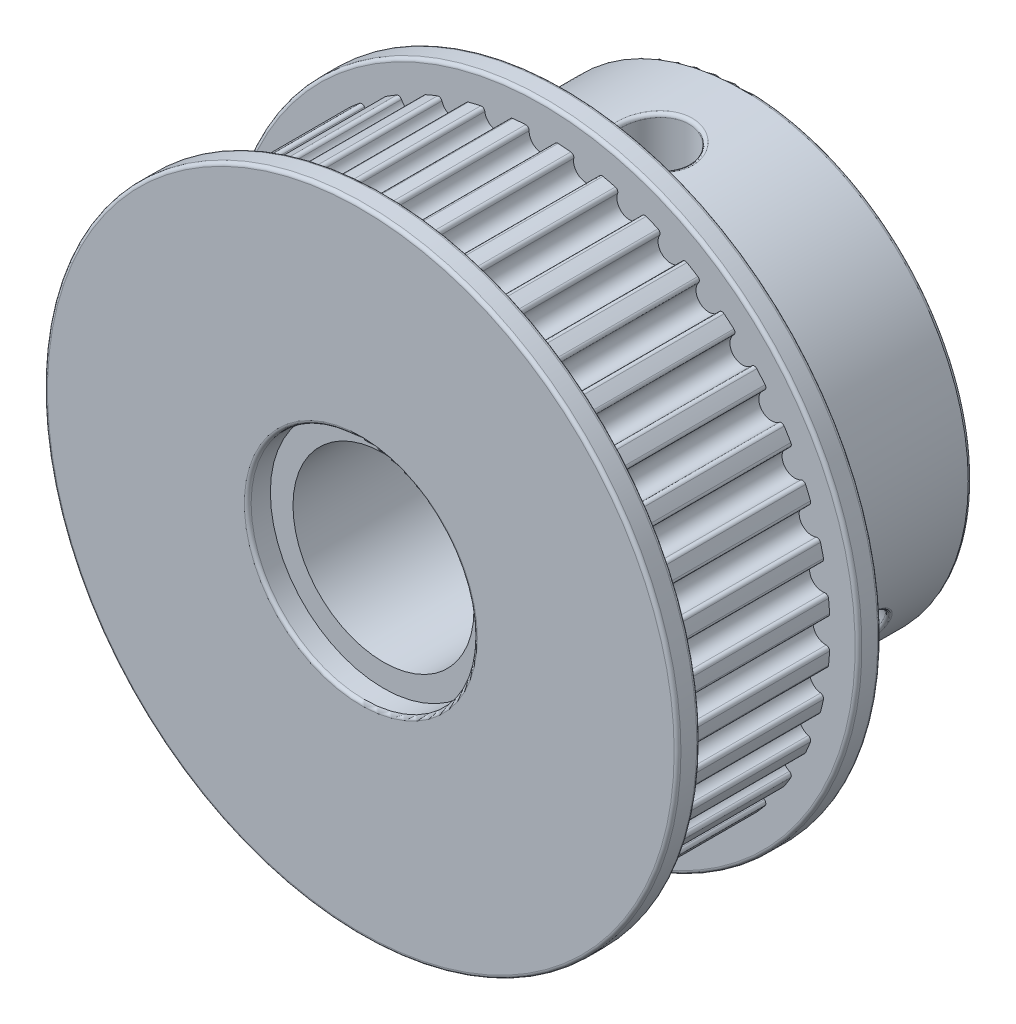
from build123d import *

# Parameters (mm, degrees)
IZIM1_R                     = 4
Y_KSEKLIK_EKSTR_ZYON1_DEPTH = 7
IZIM2_R                     = 14
IZIM2_R_2                   = 5
Y_KSEKLIK_EKSTR_ZYON2_DEPTH = 1
IZIM3_R                     = 14
IZIM3_R_2                   = 4
Y_KSEKLIK_EKSTR_ZYON3_DEPTH = 1
IZIM4_R                     = 10
IZIM4_R_2                   = 4
Y_KSEKLIK_EKSTR_ZYON4_DEPTH = 8
IZIM5_R                     = 1.5
KES_EKSTR_ZYON1_DEPTH       = 11
DAIRESEL_KAPLAMA1_COUNT     = 3
RADYUS1_R                   = 0.15


with BuildPart() as part:
    # Çizim1 → Yükseklik-Ekstrüzyon1 (new body)
    with BuildSketch(Plane.XY):
        with BuildLine():
            ThreePointArc((-0.718175382, 12.718593189), (-0.999478926, 12.699583869), (-1.280292871, 12.674353583))
            ThreePointArc((-1.280292871, 12.674353583), (-1.385311882, 12.614986985), (-1.412651738, 12.497488398))
            ThreePointArc((-1.412651738, 12.497488398), (-1.875469884, 11.841250822), (-2.518424661, 12.322351173))
            ThreePointArc((-2.518424661, 12.322351173), (-2.58073547, 12.425650489), (-2.698959772, 12.44965882))
            ThreePointArc((-2.698959772, 12.44965882), (-2.973826291, 12.386877967), (-3.247236063, 12.318029328))
            ThreePointArc((-3.247236063, 12.318029328), (-3.341675134, 12.242965039), (-3.350297563, 12.122636159))
            ThreePointArc((-3.350297563, 12.122636159), (-3.704759476, 11.402077247), (-4.415059088, 11.776674167))
            ThreePointArc((-4.415059088, 11.776674167), (-4.492762321, 11.86895414), (-4.613286816, 11.874172532))
            ThreePointArc((-4.613286816, 11.874172532), (-4.874948183, 11.769166019), (-5.134221527, 11.65839431))
            ThreePointArc((-5.134221527, 11.65839431), (-5.215755254, 11.569480661), (-5.205447943, 11.449284384))
            ThreePointArc((-5.205447943, 11.449284384), (-5.442825593, 10.682146689), (-6.202980108, 10.941016359))
            ThreePointArc((-6.202980108, 10.941016359), (-6.294162453, 11.020004749), (-6.414019428, 11.006304709))
            ThreePointArc((-6.414019428, 11.006304709), (-6.656032672, 10.861658145), (-6.894785417, 10.711690932))
            ThreePointArc((-6.894785417, 10.711690932), (-6.96140617, 10.611117273), (-6.932422918, 10.49401323))
            ThreePointArc((-6.932422918, 10.49401323), (-7.046871281, 9.699186227), (-7.838163171, 9.835954418))
            ThreePointArc((-7.838163171, 9.835954418), (-7.940579416, 9.899706267), (-8.056817595, 9.867425136))
            ThreePointArc((-8.056817595, 9.867425136), (-8.273223546, 9.686700199), (-8.485576808, 9.501230173))
            ThreePointArc((-8.485576808, 9.501230173), (-8.535644163, 9.391472961), (-8.488698634, 9.280344643))
            ThreePointArc((-8.488698634, 9.280344643), (-8.477399611, 8.477399611), (-9.280344643, 8.488698634))
            ThreePointArc((-9.280344643, 8.488698634), (-9.391472961, 8.535644163), (-9.501230173, 8.485576808))
            ThreePointArc((-9.501230173, 8.485576808), (-9.686700199, 8.273223546), (-9.867425136, 8.056817595))
            ThreePointArc((-9.867425136, 8.056817595), (-9.899706267, 7.940579416), (-9.835954418, 7.838163171))
            ThreePointArc((-9.835954418, 7.838163171), (-9.699186227, 7.046871281), (-10.49401323, 6.932422918))
            ThreePointArc((-10.49401323, 6.932422918), (-10.611117273, 6.96140617), (-10.711690932, 6.894785417))
            ThreePointArc((-10.711690932, 6.894785417), (-10.861658145, 6.656032672), (-11.006304709, 6.414019428))
            ThreePointArc((-11.006304709, 6.414019428), (-11.020004749, 6.294162453), (-10.941016359, 6.202980108))
            ThreePointArc((-10.941016359, 6.202980108), (-10.682146689, 5.442825593), (-11.449284384, 5.205447943))
            ThreePointArc((-11.449284384, 5.205447943), (-11.569480661, 5.215755254), (-11.65839431, 5.134221527))
            ThreePointArc((-11.65839431, 5.134221527), (-11.769166019, 4.874948183), (-11.874172532, 4.613286816))
            ThreePointArc((-11.874172532, 4.613286816), (-11.86895414, 4.492762321), (-11.776674167, 4.415059088))
            ThreePointArc((-11.776674167, 4.415059088), (-11.402077247, 3.704759476), (-12.122636159, 3.350297563))
            ThreePointArc((-12.122636159, 3.350297563), (-12.242965039, 3.341675134), (-12.318029328, 3.247236063))
            ThreePointArc((-12.318029328, 3.247236063), (-12.386877967, 2.973826291), (-12.44965882, 2.698959772))
            ThreePointArc((-12.44965882, 2.698959772), (-12.425650489, 2.58073547), (-12.322351173, 2.518424661))
            ThreePointArc((-12.322351173, 2.518424661), (-11.841250822, 1.875469884), (-12.497488398, 1.412651738))
            ThreePointArc((-12.497488398, 1.412651738), (-12.614986985, 1.385311882), (-12.674353583, 1.280292871))
            ThreePointArc((-12.674353583, 1.280292871), (-12.699583869, 0.999478926), (-12.718593189, 0.718175382))
            ThreePointArc((-12.718593189, 0.718175382), (-12.676386085, 0.605162347), (-12.564610997, 0.559778261))
            ThreePointArc((-12.564610997, 0.559778261), (-11.988853503, 0), (-12.564610997, -0.559778261))
            ThreePointArc((-12.564610997, -0.559778261), (-12.676386085, -0.605162347), (-12.718593189, -0.718175382))
            ThreePointArc((-12.718593189, -0.718175382), (-12.699583869, -0.999478926), (-12.674353583, -1.280292871))
            ThreePointArc((-12.674353583, -1.280292871), (-12.614986985, -1.385311882), (-12.497488398, -1.412651738))
            ThreePointArc((-12.497488398, -1.412651738), (-11.841250822, -1.875469884), (-12.322351173, -2.518424661))
            ThreePointArc((-12.322351173, -2.518424661), (-12.425650489, -2.58073547), (-12.44965882, -2.698959772))
            ThreePointArc((-12.44965882, -2.698959772), (-12.386877967, -2.973826291), (-12.318029328, -3.247236063))
            ThreePointArc((-12.318029328, -3.247236063), (-12.242965039, -3.341675134), (-12.122636159, -3.350297563))
            ThreePointArc((-12.122636159, -3.350297563), (-11.402077247, -3.704759476), (-11.776674167, -4.415059088))
            ThreePointArc((-11.776674167, -4.415059088), (-11.86895414, -4.492762321), (-11.874172532, -4.613286816))
            ThreePointArc((-11.874172532, -4.613286816), (-11.769166019, -4.874948183), (-11.65839431, -5.134221527))
            ThreePointArc((-11.65839431, -5.134221527), (-11.569480661, -5.215755254), (-11.449284384, -5.205447943))
            ThreePointArc((-11.449284384, -5.205447943), (-10.682146689, -5.442825593), (-10.941016359, -6.202980108))
            ThreePointArc((-10.941016359, -6.202980108), (-11.020004749, -6.294162453), (-11.006304709, -6.414019428))
            ThreePointArc((-11.006304709, -6.414019428), (-10.861658145, -6.656032672), (-10.711690932, -6.894785417))
            ThreePointArc((-10.711690932, -6.894785417), (-10.611117273, -6.96140617), (-10.49401323, -6.932422918))
            ThreePointArc((-10.49401323, -6.932422918), (-9.699186227, -7.046871281), (-9.835954418, -7.838163171))
            ThreePointArc((-9.835954418, -7.838163171), (-9.899706267, -7.940579416), (-9.867425136, -8.056817595))
            ThreePointArc((-9.867425136, -8.056817595), (-9.686700199, -8.273223546), (-9.501230173, -8.485576808))
            ThreePointArc((-9.501230173, -8.485576808), (-9.391472961, -8.535644163), (-9.280344643, -8.488698634))
            ThreePointArc((-9.280344643, -8.488698634), (-8.477399611, -8.477399611), (-8.488698634, -9.280344643))
            ThreePointArc((-8.488698634, -9.280344643), (-8.535644163, -9.391472961), (-8.485576808, -9.501230173))
            ThreePointArc((-8.485576808, -9.501230173), (-8.273223546, -9.686700199), (-8.056817595, -9.867425136))
            ThreePointArc((-8.056817595, -9.867425136), (-7.940579416, -9.899706267), (-7.838163171, -9.835954418))
            ThreePointArc((-7.838163171, -9.835954418), (-7.046871281, -9.699186227), (-6.932422918, -10.49401323))
            ThreePointArc((-6.932422918, -10.49401323), (-6.96140617, -10.611117273), (-6.894785417, -10.711690932))
            ThreePointArc((-6.894785417, -10.711690932), (-6.656032672, -10.861658145), (-6.414019428, -11.006304709))
            ThreePointArc((-6.414019428, -11.006304709), (-6.294162453, -11.020004749), (-6.202980108, -10.941016359))
            ThreePointArc((-6.202980108, -10.941016359), (-5.442825593, -10.682146689), (-5.205447943, -11.449284384))
            ThreePointArc((-5.205447943, -11.449284384), (-5.215755254, -11.569480661), (-5.134221527, -11.65839431))
            ThreePointArc((-5.134221527, -11.65839431), (-4.874948183, -11.769166019), (-4.613286816, -11.874172532))
            ThreePointArc((-4.613286816, -11.874172532), (-4.492762321, -11.86895414), (-4.415059088, -11.776674167))
            ThreePointArc((-4.415059088, -11.776674167), (-3.704759476, -11.402077247), (-3.350297563, -12.122636159))
            ThreePointArc((-3.350297563, -12.122636159), (-3.341675134, -12.242965039), (-3.247236063, -12.318029328))
            ThreePointArc((-3.247236063, -12.318029328), (-2.973826291, -12.386877967), (-2.698959772, -12.44965882))
            ThreePointArc((-2.698959772, -12.44965882), (-2.58073547, -12.425650489), (-2.518424661, -12.322351173))
            ThreePointArc((-2.518424661, -12.322351173), (-1.875469884, -11.841250822), (-1.412651738, -12.497488398))
            ThreePointArc((-1.412651738, -12.497488398), (-1.385311882, -12.614986985), (-1.280292871, -12.674353583))
            ThreePointArc((-1.280292871, -12.674353583), (-0.999478926, -12.699583869), (-0.718175382, -12.718593189))
            ThreePointArc((-0.718175382, -12.718593189), (-0.605162347, -12.676386085), (-0.559778261, -12.564610997))
            ThreePointArc((-0.559778261, -12.564610997), (0, -11.988853503), (0.559778261, -12.564610997))
            ThreePointArc((0.559778261, -12.564610997), (0.605162347, -12.676386085), (0.718175382, -12.718593189))
            ThreePointArc((0.718175382, -12.718593189), (0.999478926, -12.699583869), (1.280292871, -12.674353583))
            ThreePointArc((1.280292871, -12.674353583), (1.385311882, -12.614986985), (1.412651738, -12.497488398))
            ThreePointArc((1.412651738, -12.497488398), (1.875469884, -11.841250822), (2.518424661, -12.322351173))
            ThreePointArc((2.518424661, -12.322351173), (2.58073547, -12.425650489), (2.698959772, -12.44965882))
            ThreePointArc((2.698959772, -12.44965882), (2.973826291, -12.386877967), (3.247236063, -12.318029328))
            ThreePointArc((3.247236063, -12.318029328), (3.341675134, -12.242965039), (3.350297563, -12.122636159))
            ThreePointArc((3.350297563, -12.122636159), (3.704759476, -11.402077247), (4.415059088, -11.776674167))
            ThreePointArc((4.415059088, -11.776674167), (4.492762321, -11.86895414), (4.613286816, -11.874172532))
            ThreePointArc((4.613286816, -11.874172532), (4.874948183, -11.769166019), (5.134221527, -11.65839431))
            ThreePointArc((5.134221527, -11.65839431), (5.215755254, -11.569480661), (5.205447943, -11.449284384))
            ThreePointArc((5.205447943, -11.449284384), (5.442825593, -10.682146689), (6.202980108, -10.941016359))
            ThreePointArc((6.202980108, -10.941016359), (6.294162453, -11.020004749), (6.414019428, -11.006304709))
            ThreePointArc((6.414019428, -11.006304709), (6.656032672, -10.861658145), (6.894785417, -10.711690932))
            ThreePointArc((6.894785417, -10.711690932), (6.96140617, -10.611117273), (6.932422918, -10.49401323))
            ThreePointArc((6.932422918, -10.49401323), (7.046871281, -9.699186227), (7.838163171, -9.835954418))
            ThreePointArc((7.838163171, -9.835954418), (7.940579416, -9.899706267), (8.056817595, -9.867425136))
            ThreePointArc((8.056817595, -9.867425136), (8.273223546, -9.686700199), (8.485576808, -9.501230173))
            ThreePointArc((8.485576808, -9.501230173), (8.535644163, -9.391472961), (8.488698634, -9.280344643))
            ThreePointArc((8.488698634, -9.280344643), (8.477399611, -8.477399611), (9.280344643, -8.488698634))
            ThreePointArc((9.280344643, -8.488698634), (9.391472961, -8.535644163), (9.501230173, -8.485576808))
            ThreePointArc((9.501230173, -8.485576808), (9.686700199, -8.273223546), (9.867425136, -8.056817595))
            ThreePointArc((9.867425136, -8.056817595), (9.899706267, -7.940579416), (9.835954418, -7.838163171))
            ThreePointArc((9.835954418, -7.838163171), (9.699186227, -7.046871281), (10.49401323, -6.932422918))
            ThreePointArc((10.49401323, -6.932422918), (10.611117273, -6.96140617), (10.711690932, -6.894785417))
            ThreePointArc((10.711690932, -6.894785417), (10.861658145, -6.656032672), (11.006304709, -6.414019428))
            ThreePointArc((11.006304709, -6.414019428), (11.020004749, -6.294162453), (10.941016359, -6.202980108))
            ThreePointArc((10.941016359, -6.202980108), (10.682146689, -5.442825593), (11.449284384, -5.205447943))
            ThreePointArc((11.449284384, -5.205447943), (11.569480661, -5.215755254), (11.65839431, -5.134221527))
            ThreePointArc((11.65839431, -5.134221527), (11.769166019, -4.874948183), (11.874172532, -4.613286816))
            ThreePointArc((11.874172532, -4.613286816), (11.86895414, -4.492762321), (11.776674167, -4.415059088))
            ThreePointArc((11.776674167, -4.415059088), (11.402077247, -3.704759476), (12.122636159, -3.350297563))
            ThreePointArc((12.122636159, -3.350297563), (12.242965039, -3.341675134), (12.318029328, -3.247236063))
            ThreePointArc((12.318029328, -3.247236063), (12.386877967, -2.973826291), (12.44965882, -2.698959772))
            ThreePointArc((12.44965882, -2.698959772), (12.425650489, -2.58073547), (12.322351173, -2.518424661))
            ThreePointArc((12.322351173, -2.518424661), (11.841250822, -1.875469884), (12.497488398, -1.412651738))
            ThreePointArc((12.497488398, -1.412651738), (12.614986985, -1.385311882), (12.674353583, -1.280292871))
            ThreePointArc((12.674353583, -1.280292871), (12.699583869, -0.999478926), (12.718593189, -0.718175382))
            ThreePointArc((12.718593189, -0.718175382), (12.676386085, -0.605162347), (12.564610997, -0.559778261))
            ThreePointArc((12.564610997, -0.559778261), (11.988853503, 0), (12.564610997, 0.559778261))
            ThreePointArc((12.564610997, 0.559778261), (12.676386085, 0.605162347), (12.718593189, 0.718175382))
            ThreePointArc((12.718593189, 0.718175382), (12.699583869, 0.999478926), (12.674353583, 1.280292871))
            ThreePointArc((12.674353583, 1.280292871), (12.614986985, 1.385311882), (12.497488398, 1.412651738))
            ThreePointArc((12.497488398, 1.412651738), (11.841250822, 1.875469884), (12.322351173, 2.518424661))
            ThreePointArc((12.322351173, 2.518424661), (12.425650489, 2.58073547), (12.44965882, 2.698959772))
            ThreePointArc((12.44965882, 2.698959772), (12.386877967, 2.973826291), (12.318029328, 3.247236063))
            ThreePointArc((12.318029328, 3.247236063), (12.242965039, 3.341675134), (12.122636159, 3.350297563))
            ThreePointArc((12.122636159, 3.350297563), (11.402077247, 3.704759476), (11.776674167, 4.415059088))
            ThreePointArc((11.776674167, 4.415059088), (11.86895414, 4.492762321), (11.874172532, 4.613286816))
            ThreePointArc((11.874172532, 4.613286816), (11.769166019, 4.874948183), (11.65839431, 5.134221527))
            ThreePointArc((11.65839431, 5.134221527), (11.569480661, 5.215755254), (11.449284384, 5.205447943))
            ThreePointArc((11.449284384, 5.205447943), (10.682146689, 5.442825593), (10.941016359, 6.202980108))
            ThreePointArc((10.941016359, 6.202980108), (11.020004749, 6.294162453), (11.006304709, 6.414019428))
            ThreePointArc((11.006304709, 6.414019428), (10.861658145, 6.656032672), (10.711690932, 6.894785417))
            ThreePointArc((10.711690932, 6.894785417), (10.611117273, 6.96140617), (10.49401323, 6.932422918))
            ThreePointArc((10.49401323, 6.932422918), (9.699186227, 7.046871281), (9.835954418, 7.838163171))
            ThreePointArc((9.835954418, 7.838163171), (9.899706267, 7.940579416), (9.867425136, 8.056817595))
            ThreePointArc((9.867425136, 8.056817595), (9.686700199, 8.273223546), (9.501230173, 8.485576808))
            ThreePointArc((9.501230173, 8.485576808), (9.391472961, 8.535644163), (9.280344643, 8.488698634))
            ThreePointArc((9.280344643, 8.488698634), (8.477399611, 8.477399611), (8.488698634, 9.280344643))
            ThreePointArc((8.488698634, 9.280344643), (8.535644163, 9.391472961), (8.485576808, 9.501230173))
            ThreePointArc((8.485576808, 9.501230173), (8.273223546, 9.686700199), (8.056817595, 9.867425136))
            ThreePointArc((8.056817595, 9.867425136), (7.940579416, 9.899706267), (7.838163171, 9.835954418))
            ThreePointArc((7.838163171, 9.835954418), (7.046871281, 9.699186227), (6.932422918, 10.49401323))
            ThreePointArc((6.932422918, 10.49401323), (6.96140617, 10.611117273), (6.894785417, 10.711690932))
            ThreePointArc((6.894785417, 10.711690932), (6.656032672, 10.861658145), (6.414019428, 11.006304709))
            ThreePointArc((6.414019428, 11.006304709), (6.294162453, 11.020004749), (6.202980108, 10.941016359))
            ThreePointArc((6.202980108, 10.941016359), (5.442825593, 10.682146689), (5.205447943, 11.449284384))
            ThreePointArc((5.205447943, 11.449284384), (5.215755254, 11.569480661), (5.134221527, 11.65839431))
            ThreePointArc((5.134221527, 11.65839431), (4.874948183, 11.769166019), (4.613286816, 11.874172532))
            ThreePointArc((4.613286816, 11.874172532), (4.492762321, 11.86895414), (4.415059088, 11.776674167))
            ThreePointArc((4.415059088, 11.776674167), (3.704759476, 11.402077247), (3.350297563, 12.122636159))
            ThreePointArc((3.350297563, 12.122636159), (3.341675134, 12.242965039), (3.247236063, 12.318029328))
            ThreePointArc((3.247236063, 12.318029328), (2.973826291, 12.386877967), (2.698959772, 12.44965882))
            ThreePointArc((2.698959772, 12.44965882), (2.58073547, 12.425650489), (2.518424661, 12.322351173))
            ThreePointArc((2.518424661, 12.322351173), (1.875469884, 11.841250822), (1.412651738, 12.497488398))
            ThreePointArc((1.412651738, 12.497488398), (1.385311882, 12.614986985), (1.280292871, 12.674353583))
            ThreePointArc((1.280292871, 12.674353583), (0.999478926, 12.699583869), (0.718175382, 12.718593189))
            ThreePointArc((0.718175382, 12.718593189), (0.605162347, 12.676386085), (0.559778261, 12.564610997))
            ThreePointArc((0.559778261, 12.564610997), (0, 11.988853503), (-0.559778261, 12.564610997))
            ThreePointArc((-0.559778261, 12.564610997), (-0.605162347, 12.676386085), (-0.718175382, 12.718593189))
        make_face()
        Circle(IZIM1_R, mode=Mode.SUBTRACT)
    extrude(amount=Y_KSEKLIK_EKSTR_ZYON1_DEPTH)

    # Çizim2 → Yükseklik-Ekstrüzyon2 (add)
    with BuildSketch(Plane.XY.offset(7)):
        Circle(IZIM2_R)
        Circle(IZIM2_R_2, mode=Mode.SUBTRACT)
    extrude(amount=Y_KSEKLIK_EKSTR_ZYON2_DEPTH)

    # Çizim3 → Yükseklik-Ekstrüzyon3 (add)
    with BuildSketch(Plane(origin=(0, 0, 0), x_dir=(-1, 0, 0), z_dir=(0, 0, -1))):
        Circle(IZIM3_R)
        Circle(IZIM3_R_2, mode=Mode.SUBTRACT)
    extrude(amount=Y_KSEKLIK_EKSTR_ZYON3_DEPTH)

    # Çizim4 → Yükseklik-Ekstrüzyon4 (add)
    with BuildSketch(Plane(origin=(0, 0, -1), x_dir=(-1, 0, 0), z_dir=(0, 0, -1))):
        Circle(IZIM4_R)
        Circle(IZIM4_R_2, mode=Mode.SUBTRACT)
    extrude(amount=Y_KSEKLIK_EKSTR_ZYON4_DEPTH)

    # Çizim5 → Kes-Ekstrüzyon1 (cut)
    with BuildSketch(Plane(origin=(0, 0, 0), x_dir=(1, 0, 0), z_dir=(0, 1, 0))):
        with Locations((0, 5)):
            Circle(IZIM5_R)
    kes_ekstr_zyon1 = extrude(amount=KES_EKSTR_ZYON1_DEPTH, mode=Mode.SUBTRACT)

    # Dairesel Kaplama1: Kes-Ekstrüzyon1 ×3 about axis
    dairesel_kaplama1_axis = Axis((0, 0, 0), (0, 0, -1))
    for i in range(1, DAIRESEL_KAPLAMA1_COUNT):
        add(kes_ekstr_zyon1.rotate(dairesel_kaplama1_axis, i * 360 / DAIRESEL_KAPLAMA1_COUNT), mode=Mode.SUBTRACT)

    # Radyus1
    radyus1_edges = [part.edges().sort_by_distance(p)[0] for p in [
        (-14, 0, 8),
        (-14, 0, 7),
        (-5, 0, 8),
        (14, 0, -1),
        (14, 0, 0),
        (10, 0, -9),
        (4, 0, -9),
        (-1.50000004, 9.886859962, -5.000000003),
        (-7.812271871, -6.242468122, -5.000000003),
        (9.312271911, -3.64439184, -5.000000003),
    ]]
    fillet(radyus1_edges, radius=RADYUS1_R)


solid = part.part
